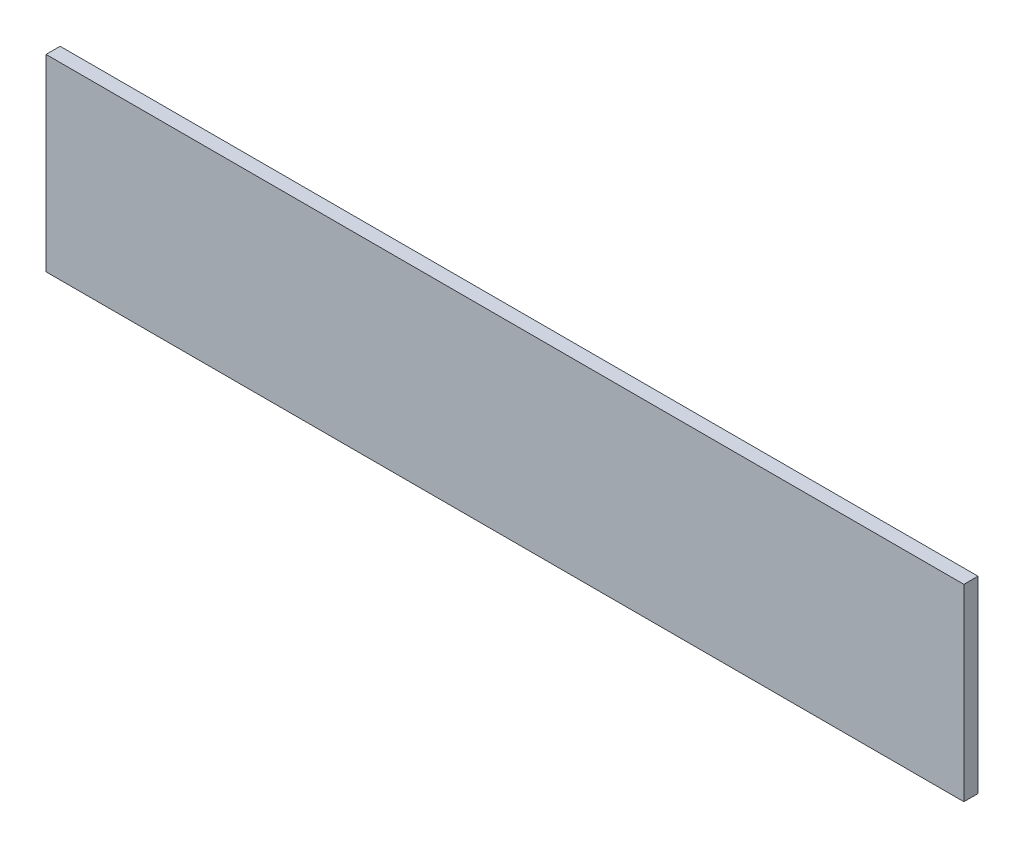
from build123d import *

# Parameters (mm, degrees)
ESQUISSE1_W        = 195
ESQUISSE1_H        = 40
BOSS_EXTRU_1_DEPTH = 3


with BuildPart() as part:
    # Esquisse1 → Boss.-Extru.1 (new body)
    with BuildSketch(Plane.XY):
        with Locations((-36.639791906, 12.110606061)):
            Rectangle(ESQUISSE1_W, ESQUISSE1_H)
    extrude(amount=BOSS_EXTRU_1_DEPTH)


solid = part.part
